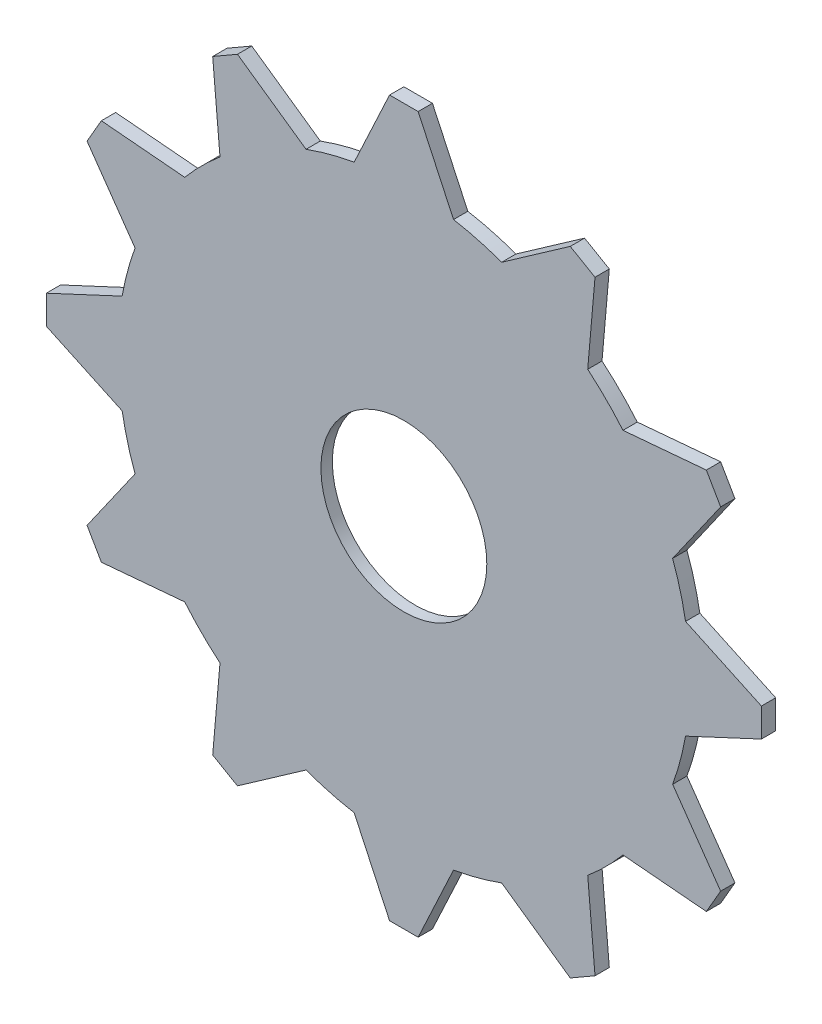
from build123d import *

# Parameters (mm, degrees)
SKETCH1_R           = 25.4
BOSS_EXTRUDE1_DEPTH = 1.27
BOSS_EXTRUDE2_DEPTH = 1.27
SKETCH3_R           = 7.366
CUT_EXTRUDE1_DEPTH  = 10
CIRPATTERN1_COUNT   = 12
SKETCH4_R           = 18.283160809
CUT_EXTRUDE2_DEPTH  = 0.254


with BuildPart() as part:
    # Sketch1 → Boss-Extrude1 (new body)
    with BuildSketch(Plane.XY):
        Circle(SKETCH1_R)
    extrude(amount=BOSS_EXTRUDE1_DEPTH)

    # Sketch2 → Boss-Extrude2 (add)
    with BuildSketch(Plane.XY.offset(1.27)):
        with BuildLine():
            Line((-1.27, 31.75), (1.27, 31.75))
            Line((1.27, 31.75), (4.411023441, 25.014053494))
            ThreePointArc((4.411023441, 25.014053494), (0, 25.4), (-4.411023441, 25.014053494))
            Line((-4.411023441, 25.014053494), (-1.27, 31.75))
        make_face()
    boss_extrude2 = extrude(amount=-BOSS_EXTRUDE2_DEPTH)

    # Sketch3 → Cut-Extrude1 (cut)
    with BuildSketch(Plane(origin=(0, 0, 0), x_dir=(-1, 0, 0), z_dir=(0, 0, -1))):
        Circle(SKETCH3_R)
    extrude(amount=-CUT_EXTRUDE1_DEPTH, mode=Mode.SUBTRACT)

    # CirPattern1: Boss-Extrude2 ×12 about axis
    cirpattern1_axis = Axis((0, 0, 0), (0, 0, 1))
    for i in range(1, CIRPATTERN1_COUNT):
        add(boss_extrude2.rotate(cirpattern1_axis, i * 360 / CIRPATTERN1_COUNT))

    # Sketch4 → Cut-Extrude2 (cut)
    with BuildSketch(Plane(origin=(0, 0, 0), x_dir=(-1, 0, 0), z_dir=(0, 0, -1))):
        Circle(SKETCH4_R)
    extrude(amount=-CUT_EXTRUDE2_DEPTH, mode=Mode.SUBTRACT)


solid = part.part
